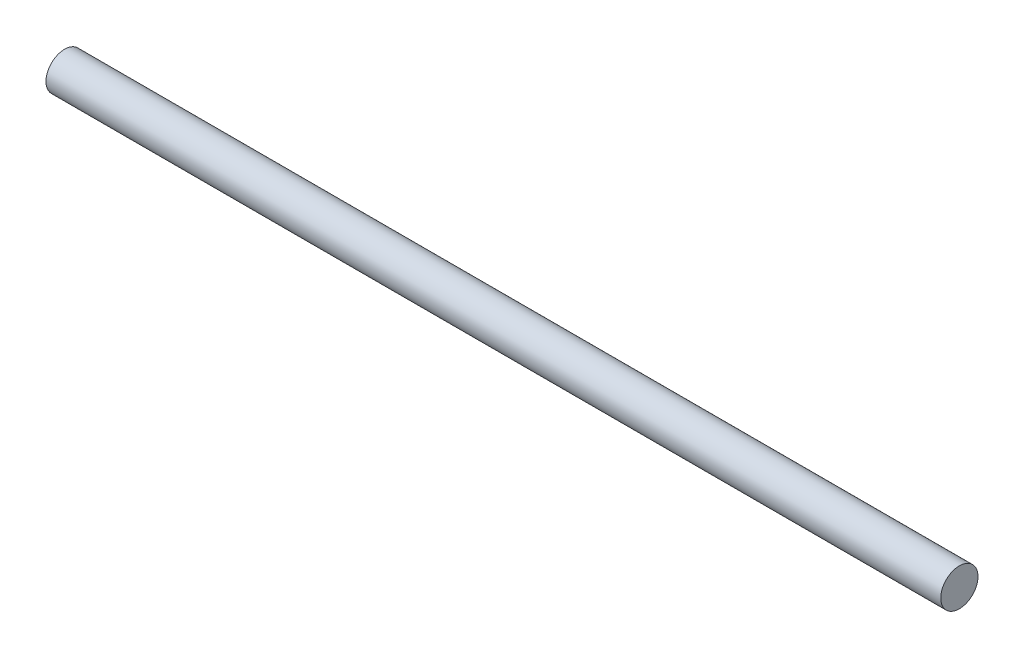
from build123d import *

# Parameters (mm, degrees)
SKETCH1_R           = 4.7625
BOSS_EXTRUDE1_DEPTH = 228.6


with BuildPart() as part:
    # Sketch1 → Boss-Extrude1 (new body)
    with BuildSketch(Plane(origin=(0, 0, 0), x_dir=(0, 0, -1), z_dir=(1, 0, 0))):
        Circle(SKETCH1_R)
    extrude(amount=BOSS_EXTRUDE1_DEPTH)


solid = part.part
